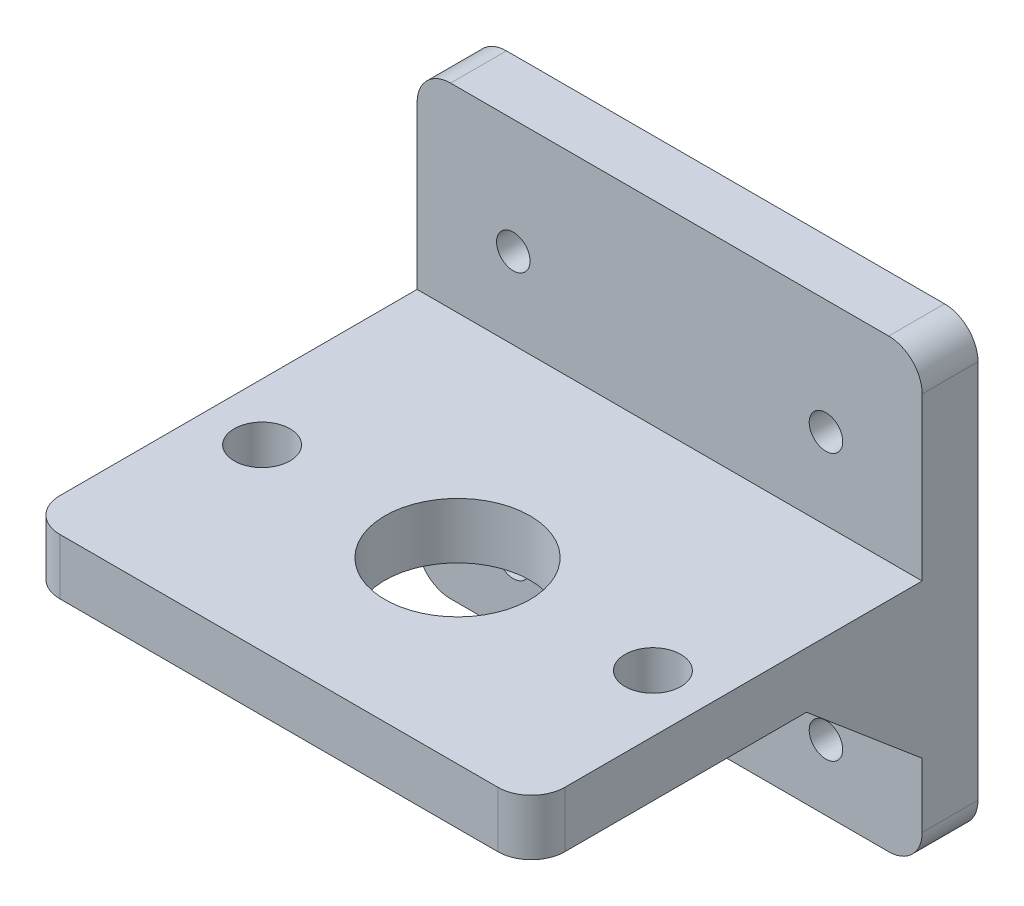
from build123d import *

# Parameters (mm, degrees)
SKETCH_1_W          = 45.233636601
SKETCH_1_H          = 40
EXTRUDE_1_DEPTH     = 5
SKETCH_2_R          = 2.5
SKETCH_2_R_2        = 6.5
CUT_EXTRUDE_1_DEPTH = 6
SKETCH_3_W          = 45.2336366
SKETCH_3_H          = 40
EXTRUDE_2_DEPTH     = 5
EXTRUDE_3_DEPTH     = 45.233637
FILLET_1_R          = 3
FILLET_3_R          = 3
SKETCH_5_R          = 1.5
CUT_EXTRUDE_2_DEPTH = 6


with BuildPart() as part:
    # 草图1 → 凸台-拉伸1 (new body)
    with BuildSketch(Plane(origin=(-84.851927107, 0, -36.561705941), x_dir=(1, 0, 0), z_dir=(0, 1, 0))):
        with Locations((834.168962127, 191.534282172)):
            Rectangle(SKETCH_1_W, SKETCH_1_H)
    extrude(amount=EXTRUDE_1_DEPTH)

    # 草图2 → 切除-拉伸1 (cut, through all)
    with BuildSketch(Plane(origin=(0, 0, 0), x_dir=(-1, 0, 0), z_dir=(0, -1, 0))):
        with Locations((-766.81703502, 224.098378246)):
            Circle(SKETCH_2_R)
        with Locations((-731.81703502, 224.098378246)):
            Circle(SKETCH_2_R)
        with Locations((-749.31703502, 224.098378246)):
            Circle(SKETCH_2_R_2)
    extrude(amount=-CUT_EXTRUDE_1_DEPTH, mode=Mode.SUBTRACT)

    # 草图3 → 凸台-拉伸2 (add)
    with BuildSketch(Plane(origin=(0, 0, -248.095988113), x_dir=(-1, 0, 0), z_dir=(0, 0, -1))):
        with Locations((-749.31703502, 2.5)):
            Rectangle(SKETCH_3_W, SKETCH_3_H)
    extrude(amount=-EXTRUDE_2_DEPTH)

    # 草图4 → 凸台-拉伸3 (add)
    with BuildSketch(Plane.ZY.offset(-726.70021672)):
        Polygon((-232.73834126, 0), (-243.095988113, -8.75), (-243.095988113, 0), align=None)
    extrude(amount=-EXTRUDE_3_DEPTH)

    # 圆角1
    fillet_1_edges = [part.edges().sort_by_distance(p)[0] for p in [
        (771.93385332, 2.5, -208.095988113),
        (726.70021672, 2.5, -208.095988113),
    ]]
    fillet(fillet_1_edges, radius=FILLET_1_R)

    # 圆角3
    fillet_3_edges = [part.edges().sort_by_distance(p)[0] for p in [
        (726.70021672, 22.5, -245.595988113),
        (771.93385332, -17.5, -245.595988113),
        (771.93385332, 22.5, -245.595988113),
        (726.70021672, -17.5, -245.595988113),
    ]]
    fillet(fillet_3_edges, radius=FILLET_3_R)

    # 草图5 → 切除-拉伸2 (cut, through all)
    with BuildSketch(Plane.XY.offset(-243.095988113)):
        with Locations((763.31703502, 12.25)):
            Circle(SKETCH_5_R)
        with Locations((763.31703502, -11.625)):
            Circle(SKETCH_5_R)
        with Locations((735.31703502, -11.625)):
            Circle(SKETCH_5_R)
        with Locations((735.31703502, 12.25)):
            Circle(SKETCH_5_R)
    extrude(amount=-CUT_EXTRUDE_2_DEPTH, mode=Mode.SUBTRACT)


solid = part.part
